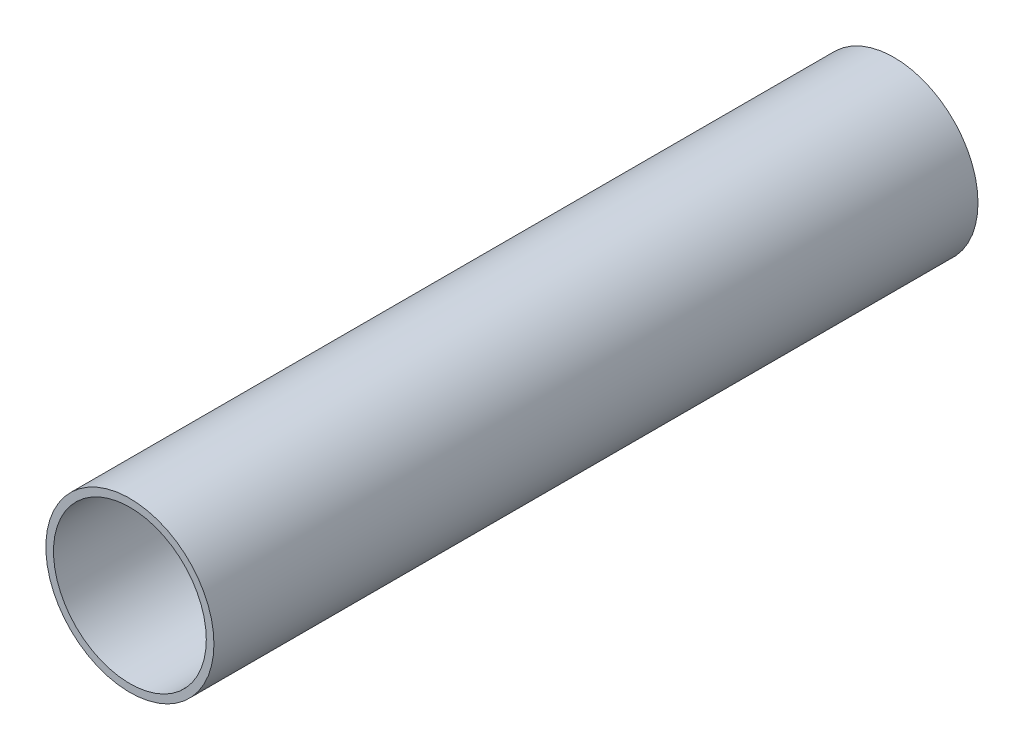
from build123d import *

# Parameters (mm, degrees)
BOSS_EXTRUDE1_DEPTH      = 25
BOSS_EXTRUDE1_DEPTH_BACK = 25
SKETCH1_R                = 5.5
SKETCH1_R_2              = 5
CUT_EXTRUDE1_DEPTH       = 27.383859304
CUT_EXTRUDE1_DEPTH_BACK  = 27.383859304
SKETCH5_R                = 10
SKETCH5_R_2              = 5.5


with BuildPart() as part:
    # Sketch1 → Boss-Extrude1 (new, two sides: drawn at the far end of the back side and taken through both)
    with BuildSketch(Plane.XY.offset(-BOSS_EXTRUDE1_DEPTH_BACK)):
        Circle(SKETCH1_R)
        Circle(SKETCH1_R_2, mode=Mode.SUBTRACT)
    extrude(amount=BOSS_EXTRUDE1_DEPTH + BOSS_EXTRUDE1_DEPTH_BACK)


with BuildPart() as body_2:
    # Sketch2 → Revolve1 (revolve)
    with BuildSketch(Plane.XY):
        with BuildLine():
            Line((5.975108931, -5.950302735), (0, -5.950302735))
            Line((0, -5.950302735), (0, -1.922251211))
            add(Edge.make_bspline(
                [(0, -1.922251211), (1.113001322, -1.956271274), (2.204544845, -4.193448832), (4.835203148, -5.950302735), (5.975108931, -5.950302735)],
                knots=[0, 0, 0, 0, 0.401420873, 1, 1, 1, 1], degree=3))
        make_face()
    revolve(axis=Axis((0, 2.861542665, 0), (0, -1, 0)))

    # Sketch5 → Cut-Extrude1 (cut, two sides: drawn at the far end of the back side and taken through both)
    with BuildSketch(Plane.XY.offset(-CUT_EXTRUDE1_DEPTH_BACK)):
        Circle(SKETCH5_R)
        Circle(SKETCH5_R_2, mode=Mode.SUBTRACT)
    extrude(amount=CUT_EXTRUDE1_DEPTH + CUT_EXTRUDE1_DEPTH_BACK, mode=Mode.SUBTRACT)


solid = Compound([part.part, body_2.part])
